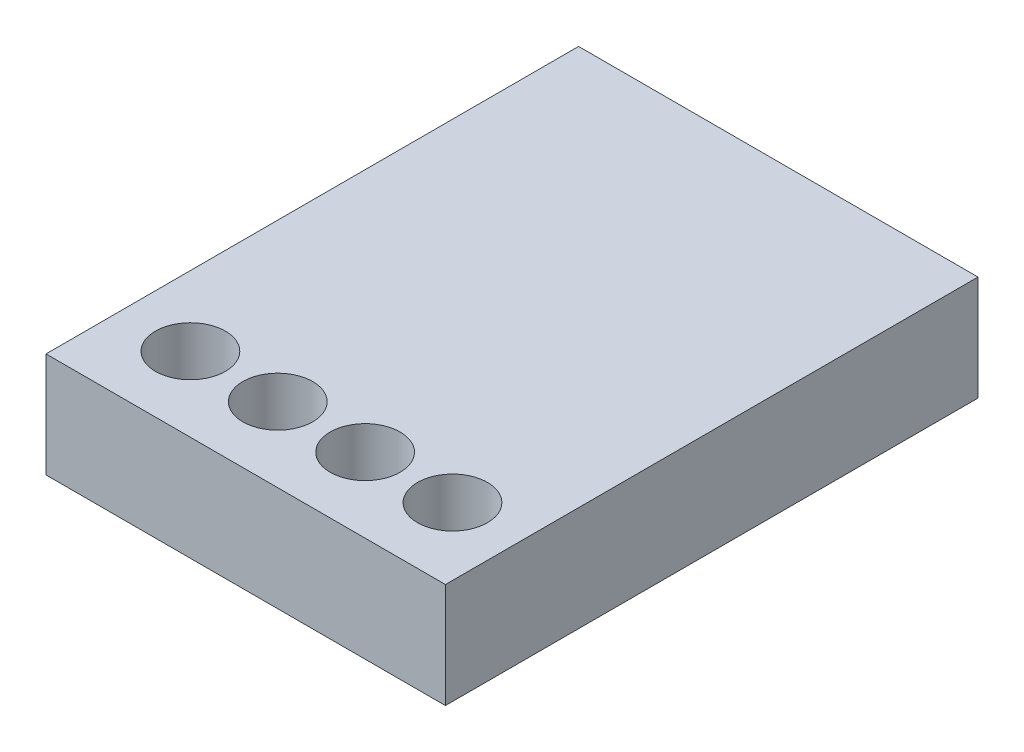
from build123d import *

# Parameters (mm, degrees)
SKETCH1_W           = 11.43
SKETCH1_H           = 15.24
BOSS_EXTRUDE1_DEPTH = 3
SKETCH2_R           = 1
CUT_EXTRUDE1_DEPTH  = 10


with BuildPart() as part:
    # Sketch1 → Boss-Extrude1 (new body)
    with BuildSketch(Plane(origin=(0, 0, 0), x_dir=(1, 0, 0), z_dir=(0, 1, 0))):
        with Locations((-0.179216028, -3.259076655)):
            Rectangle(SKETCH1_W, SKETCH1_H)
    extrude(amount=BOSS_EXTRUDE1_DEPTH)

    # Sketch2 → Cut-Extrude1 (cut)
    with BuildSketch(Plane(origin=(0, 3, 0), x_dir=(1, 0, 0), z_dir=(0, 1, 0))):
        with Locations((-3.894216028, -8.747068679)):
            Circle(SKETCH2_R)
        with Locations((-1.394216028, -8.747068679)):
            Circle(SKETCH2_R)
        with Locations((1.105783972, -8.747068679)):
            Circle(SKETCH2_R)
        with Locations((3.605783972, -8.747068679)):
            Circle(SKETCH2_R)
    extrude(amount=-CUT_EXTRUDE1_DEPTH, mode=Mode.SUBTRACT)


solid = part.part
